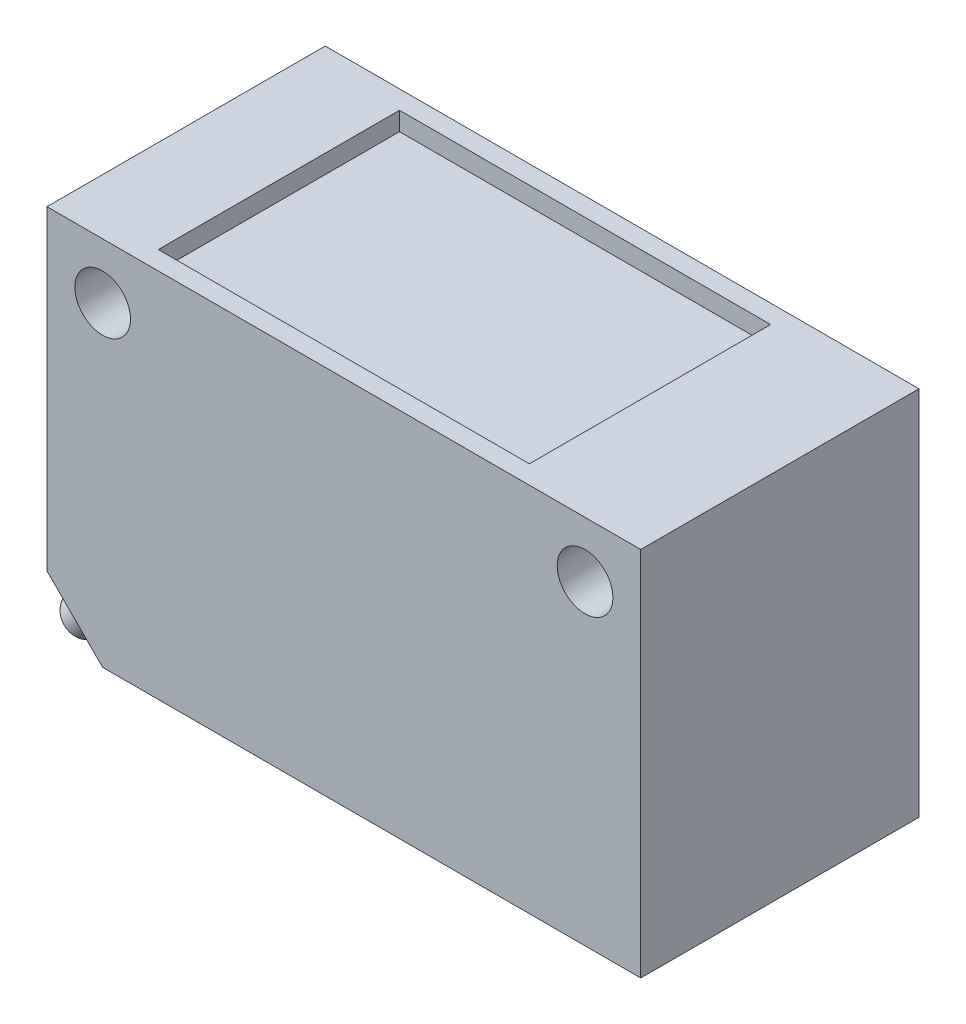
from build123d import *

# Parameters (mm, degrees)
ESQUISSE2_W             = 32
ESQUISSE2_H             = 20
BOSS_EXTRU_1_DEPTH      = 15
ESQUISSE3_R             = 1.5
ENL_V_MAT_EXTRU_1_DEPTH = 15
CHANFREIN1_SIZE         = 3
ESQUISSE5_R             = 1
BOSS_EXTRU_2_DEPTH      = 10
ESQUISSE6_W             = 20
ESQUISSE6_H             = 13
ENL_V_MAT_EXTRU_2_DEPTH = 1


with BuildPart() as part:
    # Esquisse2 → Boss.-Extru.1 (new body)
    with BuildSketch(Plane.XY):
        Rectangle(ESQUISSE2_W, ESQUISSE2_H)
    extrude(amount=BOSS_EXTRU_1_DEPTH)

    # Esquisse3 → Enlèv. mat.-Extru.1 (cut)
    with BuildSketch(Plane.XY.offset(15)):
        with Locations((-13, 7)):
            Circle(ESQUISSE3_R)
    enl_v_mat_extru_1 = extrude(amount=-ENL_V_MAT_EXTRU_1_DEPTH, mode=Mode.SUBTRACT)

    # Symétrie1: Enlèv. mat.-Extru.1 across plane
    add(enl_v_mat_extru_1.mirror(Plane(origin=(0, 0, 0), x_dir=(0, 0, 1), z_dir=(1, 0, 0))), mode=Mode.SUBTRACT)

    # Chanfrein1
    chanfrein1_edges = [part.edges().sort_by_distance(p)[0] for p in [
        (-16, -10, 7.5),
    ]]
    chamfer(chanfrein1_edges, length=CHANFREIN1_SIZE)

    # Esquisse5 → Boss.-Extru.2 (add)
    with BuildSketch(Plane(origin=(-11.5, -11.5, 0), x_dir=(0, 0, 1), z_dir=(-0.707106781, -0.707106781, 0))):
        with Locations((7.5, 4.241320344)):
            Circle(ESQUISSE5_R)
    extrude(amount=BOSS_EXTRU_2_DEPTH)

    # Esquisse6 → Enlèv. mat.-Extru.2 (cut)
    with BuildSketch(Plane(origin=(0, 10, 0), x_dir=(1, 0, 0), z_dir=(0, 1, 0))):
        with Locations((-1, -7.5)):
            Rectangle(ESQUISSE6_W, ESQUISSE6_H)
    extrude(amount=-ENL_V_MAT_EXTRU_2_DEPTH, mode=Mode.SUBTRACT)


solid = part.part
